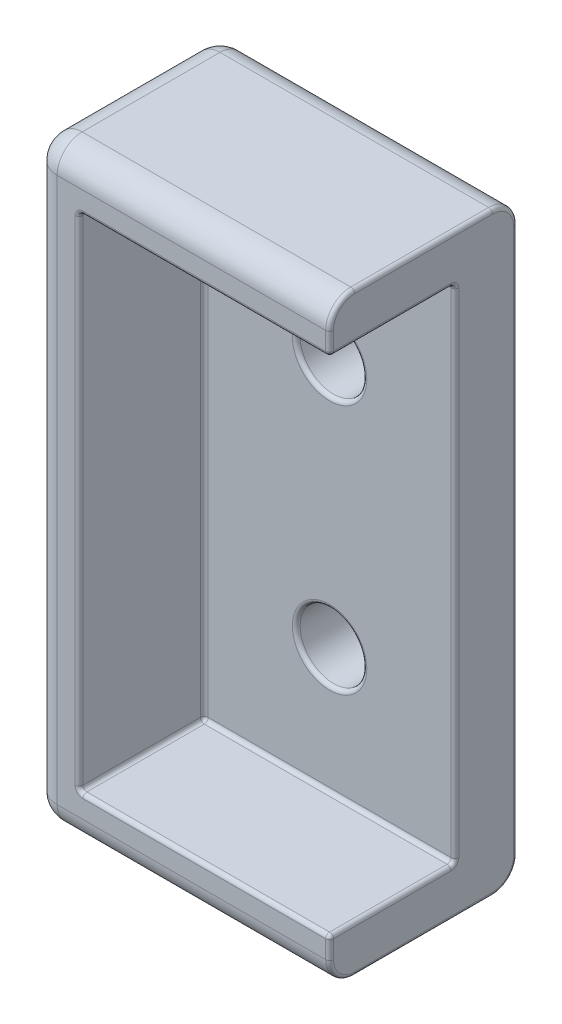
from build123d import *

# Parameters (mm, degrees)
SKETCH1_W                   = 30.1625
SKETCH1_H                   = 60.325
BOSS_EXTRUDE1_DEPTH         = 19.05
SKETCH1_3_W                 = 25.4
SKETCH1_3_H                 = 50.8
CUT_EXTRUDE1_DEPTH          = 12.7
F_1_4_CLEARANCE_HOLE1_D     = 6.7564
F_1_4_CLEARANCE_HOLE1_DEPTH = 29.9974
F_1_4_CLEARANCE_HOLE1_TIP   = 2.029827343
FILLET1_R                   = 2.54
FILLET2_R                   = 0.396875


with BuildPart() as part:
    # Sketch1 → Boss-Extrude1 (new body)
    with BuildSketch(Plane.XY):
        with Locations((-15.08125, 0)):
            Rectangle(SKETCH1_W, SKETCH1_H)
    extrude(amount=-BOSS_EXTRUDE1_DEPTH)

    # Sketch1_3 → Cut-Extrude1 (cut)
    with BuildSketch(Plane.XY):
        with Locations((-12.7, 0)):
            Rectangle(SKETCH1_3_W, SKETCH1_3_H)
    extrude(amount=-CUT_EXTRUDE1_DEPTH, mode=Mode.SUBTRACT)

    # 1_4 Clearance Hole1
    with Locations(Plane.XY.offset(-12.7)):
        with Locations((-12.7, 12.7), (-12.7, -12.7)):
            Hole(F_1_4_CLEARANCE_HOLE1_D / 2, depth=F_1_4_CLEARANCE_HOLE1_DEPTH)
            with Locations((0, 0, -(F_1_4_CLEARANCE_HOLE1_DEPTH + F_1_4_CLEARANCE_HOLE1_TIP / 2))):  # 118° drill point
                Cone(0, F_1_4_CLEARANCE_HOLE1_D / 2, F_1_4_CLEARANCE_HOLE1_TIP, mode=Mode.SUBTRACT)

    # Fillet1
    fillet1_edges = [part.edges().sort_by_distance(p)[0] for p in [
        (-30.1625, 0, 0),
        (-15.08125, 30.1625, 0),
        (-15.08125, -30.1625, 0),
        (-15.08125, -30.1625, -19.05),
        (-30.1625, -30.1625, -9.525),
        (-30.1625, 30.1625, -9.525),
        (-15.08125, 30.1625, -19.05),
        (-30.1625, 0, -19.05),
    ]]
    fillet(fillet1_edges, radius=FILLET1_R)

    # Fillet2
    fillet2_edges = [part.edges().sort_by_distance(p)[0] for p in [
        (-12.7, 25.4, 0),
        (-12.7, -25.4, 0),
        (0, 29.418551224, -18.306051224),
        (0, 0, -19.05),
        (0, -29.418551224, -18.306051224),
        (0, -30.1625, -9.525),
        (0, -29.418551224, -0.743948776),
        (0, -26.51125, 0),
        (0, -25.4, -6.35),
        (0, 25.4, -6.35),
        (0, 26.51125, 0),
        (0, 29.418551224, -0.743948776),
        (0, 30.1625, -9.525),
        (-12.7, 25.4, -12.7),
        (0, 0, -12.7),
        (-12.7, -25.4, -12.7),
        (-25.4, 25.4, -6.35),
        (-25.4, 0, -12.7),
        (-25.4, -25.4, -6.35),
        (-25.4, 0, 0),
        (-9.3218, -12.7, -12.7),
        (-9.3218, 12.7, -12.7),
        (-9.3218, -12.7, -19.05),
        (-9.3218, 12.7, -19.05),
    ]]
    fillet(fillet2_edges, radius=FILLET2_R)


solid = part.part
